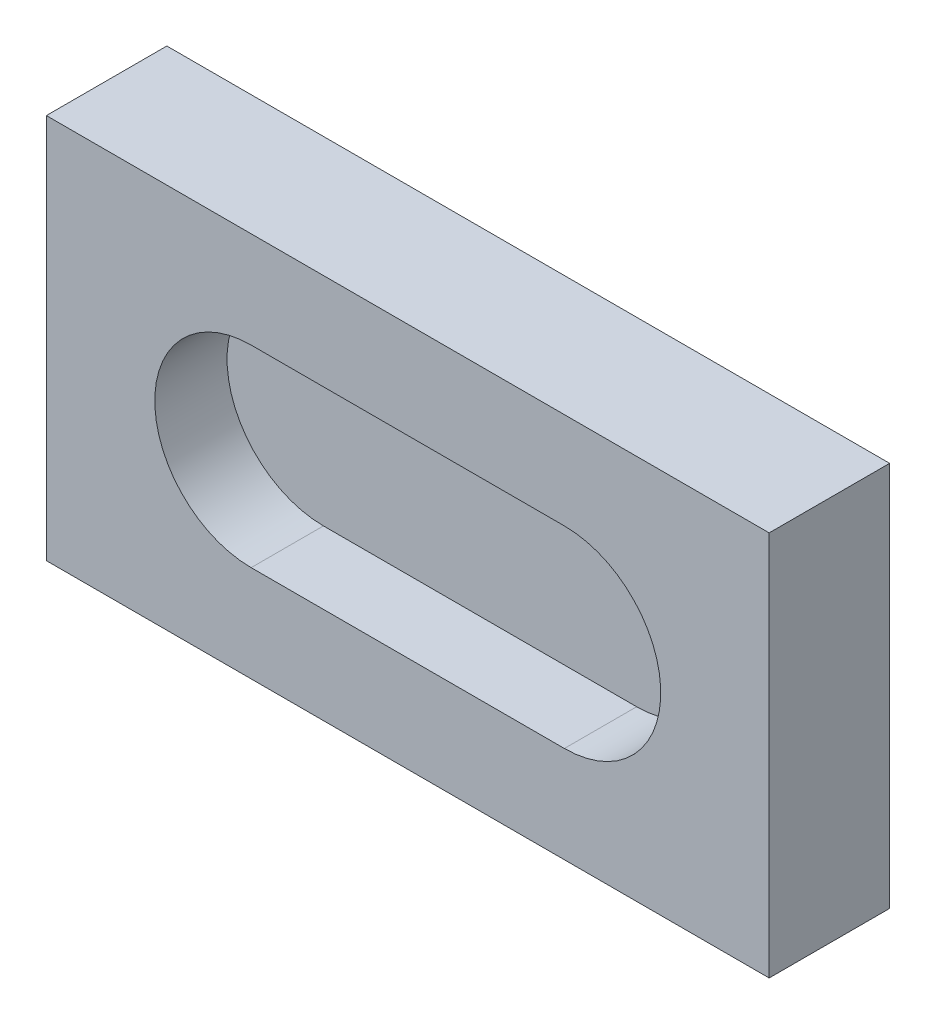
from build123d import *

# Parameters (mm, degrees)
SKETCH_1_W          = 150
SKETCH_1_H          = 80
EXTRUDE_1_DEPTH     = 25
CUT_EXTRUDE_1_DEPTH = 15
MOVE_BODY_1_ANGLE   = 90


with BuildPart() as part:
    # 草图1 → 凸台-拉伸1 (new body)
    with BuildSketch(Plane(origin=(0, 0, 0), x_dir=(1, 0, 0), z_dir=(0, 1, 0))):
        Rectangle(SKETCH_1_W, SKETCH_1_H)
    extrude(amount=EXTRUDE_1_DEPTH)

    # 草图2 → 切除-拉伸1 (cut)
    with BuildSketch(Plane(origin=(0, 25, 0), x_dir=(1, 0, 0), z_dir=(0, 1, 0))):
        with BuildLine():
            Line((-32.5, 20), (32.5, 20))
            ThreePointArc((32.5, 20), (52.5, 0), (32.5, -20))
            Line((32.5, -20), (-32.5, -20))
            ThreePointArc((-32.5, -20), (-52.5, 0), (-32.5, 20))
        make_face()
    extrude(amount=-CUT_EXTRUDE_1_DEPTH, mode=Mode.SUBTRACT)


with BuildPart() as part_1:
    # Move Body 1: moved
    add(part.part.rotate(Axis((0, 12.5, 0), (1, 0, 0)), MOVE_BODY_1_ANGLE))


solid = part_1.part
